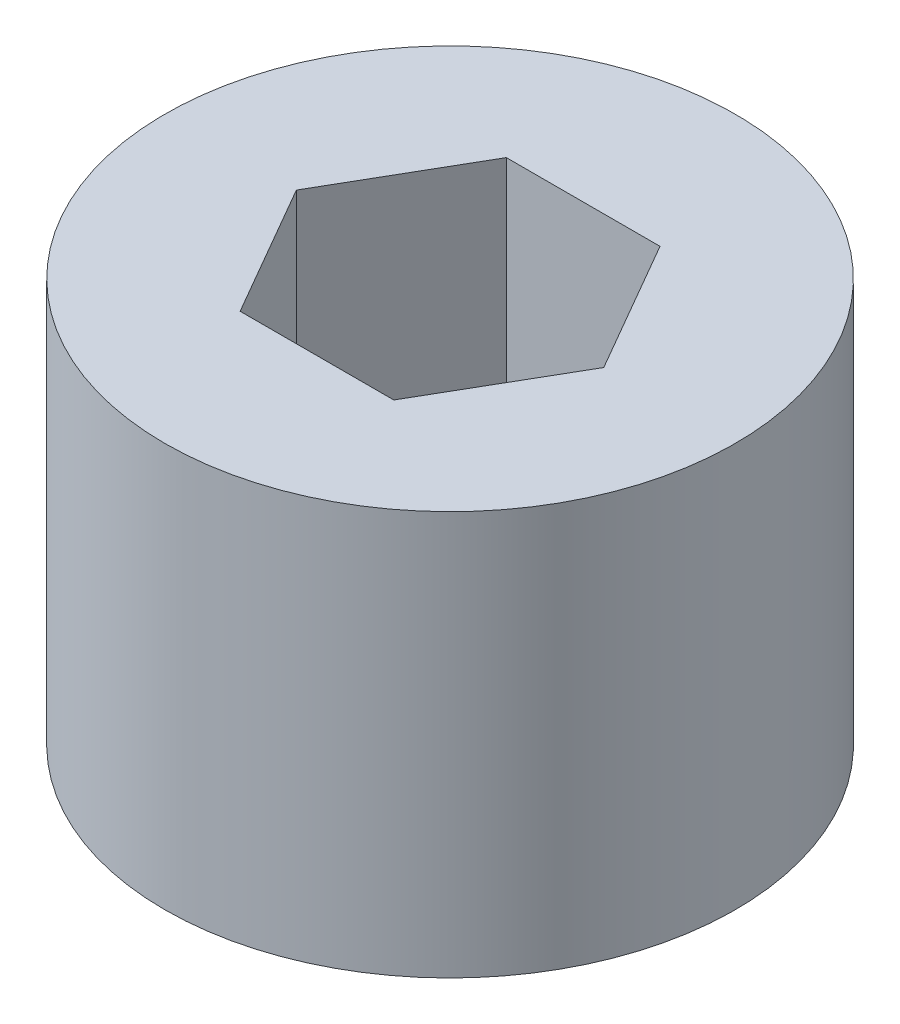
from build123d import *

# Parameters (mm, degrees)
SKETCH1_R               = 15
BOSS_EXTRUDE1_DEPTH     = 21.24
CUT_EXTRUDE1_DEPTH      = 26
CUT_EXTRUDE1_DEPTH_BACK = 32


with BuildPart() as part:
    # Sketch1 → Boss-Extrude1 (new body)
    with BuildSketch(Plane(origin=(0, 0, 0), x_dir=(1, 0, 0), z_dir=(0, 1, 0))):
        Circle(SKETCH1_R)
    extrude(amount=BOSS_EXTRUDE1_DEPTH)

    # Sketch3 → Cut-Extrude1 (cut, two sides)
    with BuildSketch(Plane(origin=(0, 21.24, 0), x_dir=(1, 0, 0), z_dir=(0, 1, 0))) as cut_extrude1_sk:
        Polygon((8.082903769, 0), (4.041451884, 7), (-4.041451884, 7), (-8.082903769, 0), (-4.041451884, -7), (4.041451884, -7), align=None)
    extrude(amount=CUT_EXTRUDE1_DEPTH, mode=Mode.SUBTRACT)
    extrude(cut_extrude1_sk.sketch, amount=-CUT_EXTRUDE1_DEPTH_BACK, mode=Mode.SUBTRACT)


solid = part.part
